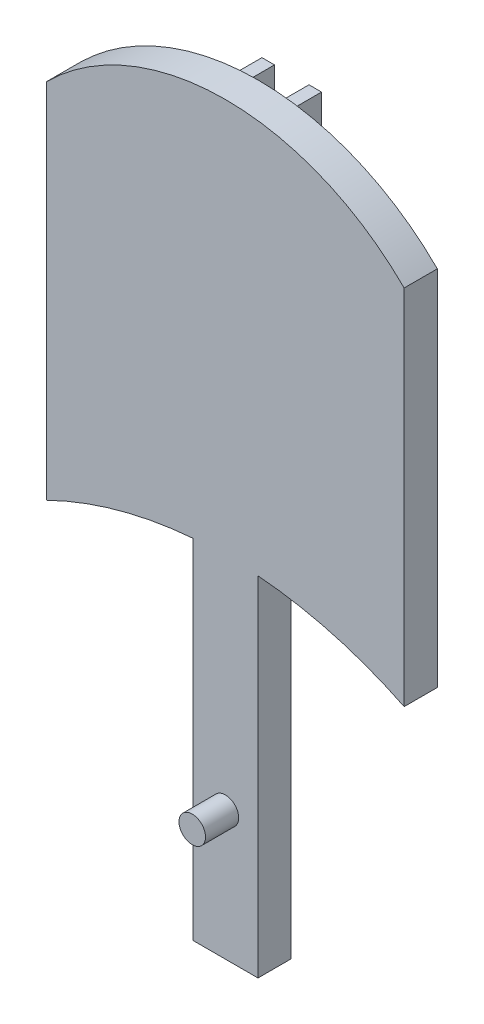
from build123d import *

# Parameters (mm, degrees)
BOSS_EXTRUDE1_DEPTH = 3.175
BOSS_EXTRUDE2_DEPTH = 3.175
SKETCH3_W           = 6.236959702
SKETCH3_H           = 47.194711522
BOSS_EXTRUDE3_DEPTH = 3.175
SKETCH4_R           = 1.27
BOSS_EXTRUDE4_DEPTH = 3.175


with BuildPart() as part:
    # Sketch1 → Boss-Extrude1 (new body)
    with BuildSketch(Plane.XY):
        with BuildLine():
            Line((-17.114253333, -17.357583949), (-17.114253333, 17.357583949))
            ThreePointArc((-17.114253333, 17.357583949), (0, 24.432200125), (17.114253333, 17.357583949))
            Line((17.114253333, 17.357583949), (17.114253333, -17.357583949))
            ThreePointArc((17.114253333, -17.357583949), (0, -13.382802691), (-17.114253333, -17.357583949))
        make_face()
    extrude(amount=BOSS_EXTRUDE1_DEPTH)

    # Sketch2 → Boss-Extrude2 (add)
    with BuildSketch(Plane(origin=(0, 0, 0), x_dir=(-1, 0, 0), z_dir=(0, 0, -1))):
        with BuildLine():
            Line((-1.65128862, -13.417928303), (-1.65128862, 22.268343179))
            Line((-1.65128862, 22.268343179), (-1.65128862, 23.29835294))
            Line((-1.65128862, 23.29835294), (-2.853426735, 23.29835294))
            Line((-2.853426735, 23.29835294), (-2.853426735, -13.48778167))
            ThreePointArc((-2.853426735, -13.48778167), (-2.25262846, -13.448194961), (-1.65128862, -13.417928303))
        make_face()
        with BuildLine():
            Line((1.65128862, 23.29835294), (1.65128862, 22.268343179))
            Line((1.65128862, 22.268343179), (1.65128862, -13.417928303))
            ThreePointArc((1.65128862, -13.417928303), (2.25262846, -13.448194961), (2.853426735, -13.48778167))
            Line((2.853426735, -13.48778167), (2.853426735, 23.29835294))
            Line((2.853426735, 23.29835294), (1.65128862, 23.29835294))
        make_face()
    extrude(amount=BOSS_EXTRUDE2_DEPTH)

    # Sketch3 → Boss-Extrude3 (add)
    with BuildSketch(Plane.XY.offset(3.175)):
        with Locations((0, -23.258467244)):
            Rectangle(SKETCH3_W, SKETCH3_H)
    extrude(amount=-BOSS_EXTRUDE3_DEPTH)

    # Sketch4 → Boss-Extrude4 (add)
    with BuildSketch(Plane.XY.offset(3.175)):
        with Locations((0, -34.503683415)):
            Circle(SKETCH4_R)
    extrude(amount=BOSS_EXTRUDE4_DEPTH)


solid = part.part
